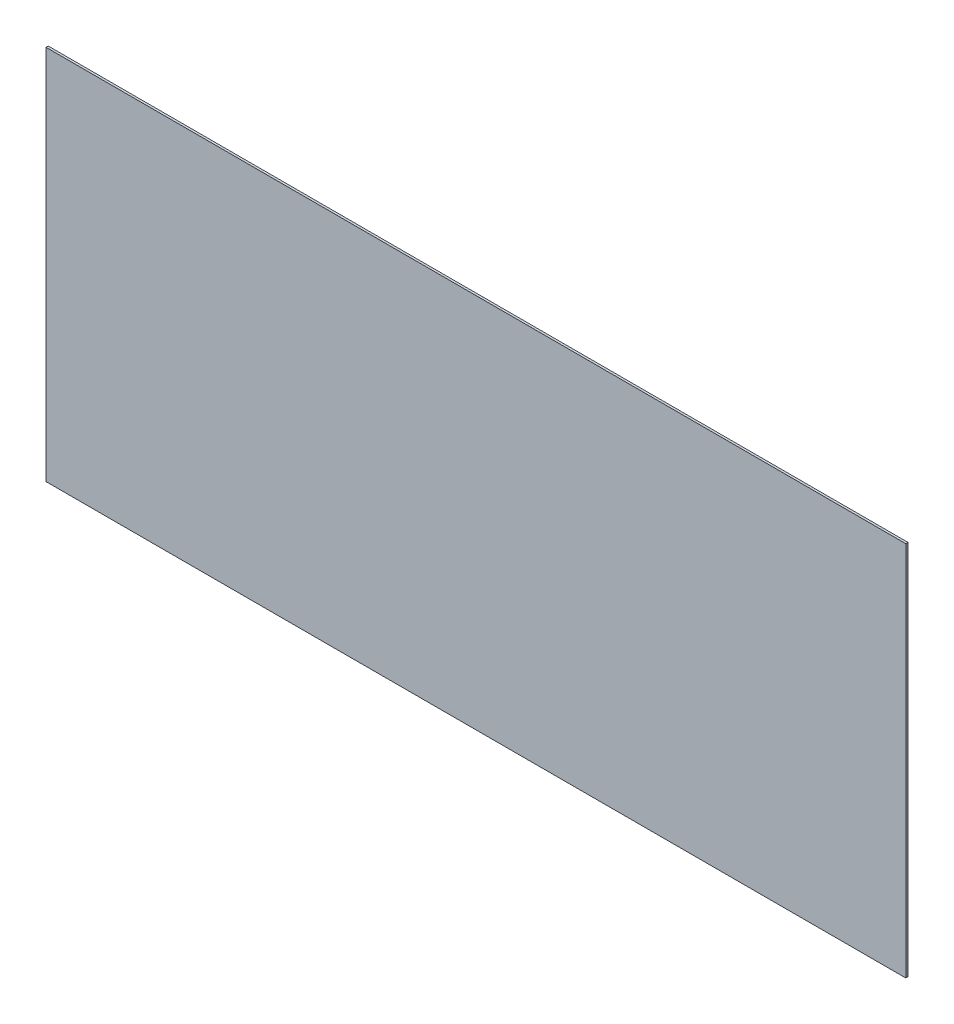
from build123d import *

# Parameters (mm, degrees)
SKETCH1_W           = 1219.2
SKETCH1_H           = 533.4
BOSS_EXTRUDE1_DEPTH = 3.175


with BuildPart() as part:
    # Sketch1 → Boss-Extrude1 (new body)
    with BuildSketch(Plane.XY):
        with Locations((609.6, 266.7)):
            Rectangle(SKETCH1_W, SKETCH1_H)
    extrude(amount=BOSS_EXTRUDE1_DEPTH)


solid = part.part
